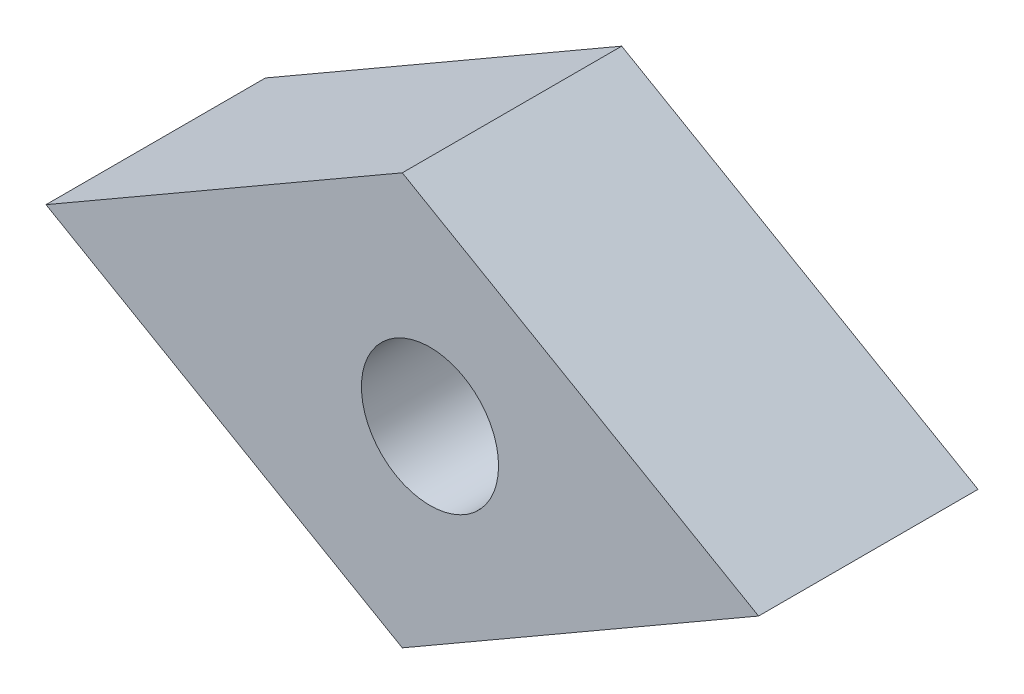
from build123d import *

# Parameters (mm, degrees)
EXTRUDE_1_DEPTH           = 8
HOLE_WIZARD_3_D           = 3
HOLE_WIZARD_3_DEPTH       = 9
HOLE_WIZARD_3_CBORE_D     = 5
HOLE_WIZARD_3_CBORE_DEPTH = 4


with BuildPart() as part:
    # 草图1 → 凸台-拉伸1 (new body)
    with BuildSketch(Plane.XY):
        Polygon((0, 7.5), (-12.990381057, 0), (0, -7.5), (12.990381057, 0), align=None)
    extrude(amount=EXTRUDE_1_DEPTH)

    # 孔3
    with Locations(Plane(origin=(1.009618943, 0, 8), x_dir=(1, 0, 0), z_dir=(0, 0, 1))):
        with Locations((0, 0)):
            CounterBoreHole(HOLE_WIZARD_3_D / 2, HOLE_WIZARD_3_CBORE_D / 2, HOLE_WIZARD_3_CBORE_DEPTH, depth=HOLE_WIZARD_3_DEPTH)


solid = part.part
